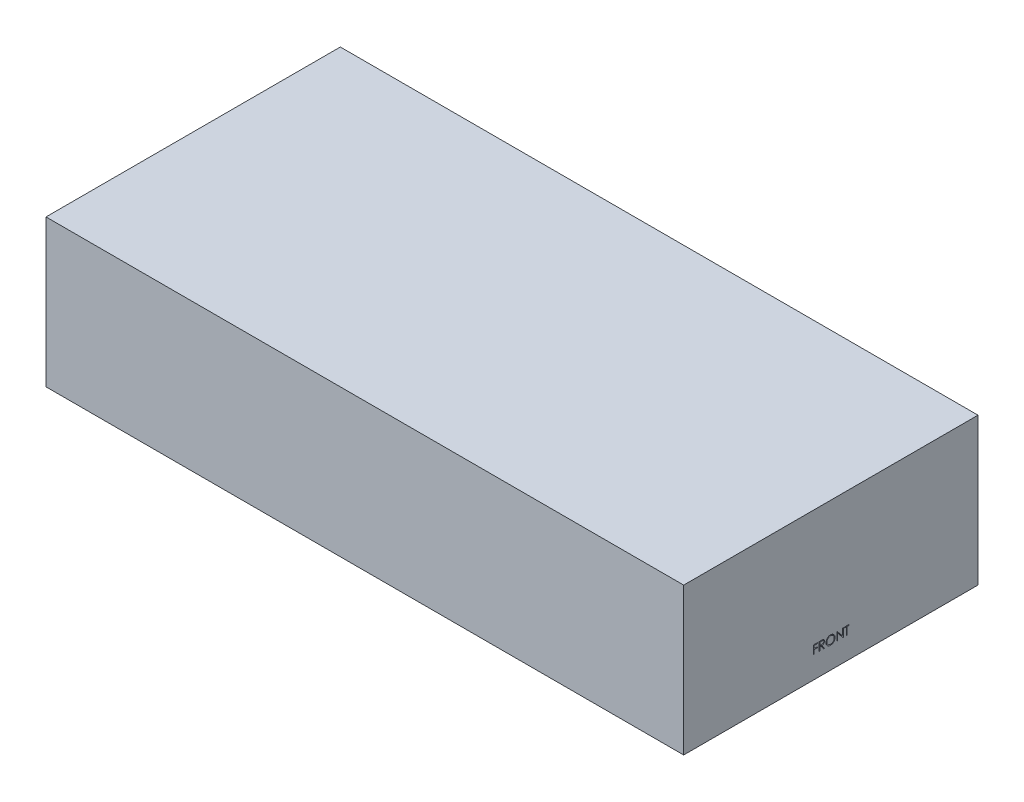
from build123d import *

# Parameters (mm, degrees)
SKETCH1_W           = 260
SKETCH1_H           = 120
BOSS_EXTRUDE1_DEPTH = 60
CUT_EXTRUDE1_DEPTH  = 1


with BuildPart() as part:
    # Sketch1 → Boss-Extrude1 (new body)
    with BuildSketch(Plane(origin=(0, 0, 0), x_dir=(1, 0, 0), z_dir=(0, 1, 0))):
        Rectangle(SKETCH1_W, SKETCH1_H)
    extrude(amount=BOSS_EXTRUDE1_DEPTH)

    # Sketch2 → Cut-Extrude1 (cut)
    # profile 1 of 5: a face of its own
    with BuildSketch(Plane(origin=(130, 0, 0), x_dir=(0, 0, -1), z_dir=(1, 0, 0))):
        Polygon((-7.08974359, 12.415972118), (-5.384615385, 12.415972118), (-5.384615385, 12.056997759), (-6.775641026, 12.056997759), (-6.775641026, 10.980074682), (-5.384615385, 10.980074682), (-5.384615385, 10.621100323), (-6.775641026, 10.621100323), (-6.775641026, 8.915972118), (-7.08974359, 8.915972118), align=None)
    # profile 2 of 5: a face of its own
    with BuildSketch(Plane(origin=(130, 0, 0), x_dir=(0, 0, -1), z_dir=(1, 0, 0))):
        with BuildLine():
            Line((-4.756410256, 12.415972118), (-4.055989583, 12.415972118))
            add(Edge.make_bspline(
                [(-4.055989583, 12.415972118), (-4.009248455, 12.415816532), (-3.91950031, 12.41551779), (-3.79092704, 12.413852027), (-3.674099943, 12.409077671), (-3.569080104, 12.404969088), (-3.475869449, 12.397477147), (-3.394182158, 12.390316499), (-3.324394461, 12.380942839), (-3.282148609, 12.372237416), (-3.263020833, 12.368295836)],
                knots=[0, 0, 0, 0, 1.410062039, 2.707475311, 3.878576406, 4.937260626, 5.877586885, 6.699081471, 7.410979367, 8, 8, 8, 8], degree=3))
            add(Edge.make_bspline(
                [(-3.263020833, 12.368295836), (-3.237414209, 12.361969071), (-3.18674722, 12.349450507), (-3.113797154, 12.322990906), (-3.04428283, 12.292371282), (-2.978493005, 12.256407561), (-2.916757214, 12.214832782), (-2.858438903, 12.168364659), (-2.80327344, 12.117257454), (-2.75349181, 12.060222612), (-2.706552758, 12.000386102), (-2.666964132, 11.935682346), (-2.632837652, 11.868020818), (-2.605667135, 11.7967134), (-2.583789161, 11.722451628), (-2.568362922, 11.644562832), (-2.559111734, 11.563401857), (-2.558169879, 11.508043948), (-2.557692308, 11.479974522)],
                knots=[0, 0, 0, 0, 1.027469482, 2.033020251, 3.019912614, 3.986113645, 4.951240523, 5.91722682, 6.890402269, 7.87763091, 8.8651537, 9.85103654, 10.82876324, 11.815024772, 12.821070561, 13.842952187, 14.906261191, 16, 16, 16, 16], degree=3))
            add(Edge.make_bspline(
                [(-2.557692308, 11.479974522), (-2.559161306, 11.433339418), (-2.562027702, 11.34234225), (-2.588752805, 11.210281368), (-2.632529325, 11.087092054), (-2.692852614, 10.972929416), (-2.76967209, 10.87001877), (-2.861996881, 10.779628315), (-2.969878492, 10.703988402), (-3.070307808, 10.651535598), (-3.159022008, 10.617942689), (-3.232055321, 10.59430633), (-3.311722298, 10.576044365), (-3.397259633, 10.559684233), (-3.489023288, 10.547332539), (-3.586793328, 10.538285944), (-3.690639479, 10.532631896), (-3.761978549, 10.531789891), (-3.798677885, 10.531356734)],
                knots=[0, 0, 0, 0, 1.260483769, 2.459530307, 3.627416485, 4.787058657, 5.939039949, 7.08810263, 8.267026773, 9.491475466, 10.141966685, 10.831826277, 11.566392101, 12.351337768, 13.187381173, 14.07005841, 15.007169909, 16, 16, 16, 16], degree=3))
            Line((-3.798677885, 10.531356734), (-2.512820513, 8.915972118))
            Line((-2.512820513, 8.915972118), (-2.901241987, 8.915972118))
            Line((-2.901241987, 8.915972118), (-4.187099359, 10.531356734))
            Line((-4.187099359, 10.531356734), (-4.442307692, 10.531356734))
            Line((-4.442307692, 10.531356734), (-4.442307692, 8.915972118))
            Line((-4.442307692, 8.915972118), (-4.756410256, 8.915972118))
            Line((-4.756410256, 8.915972118), (-4.756410256, 12.415972118))
        make_face()
        with BuildLine():
            Line((-4.442307692, 12.056997759), (-4.442307692, 10.890331093))
            Line((-4.442307692, 10.890331093), (-3.801482372, 10.88542324))
            add(Edge.make_bspline(
                [(-3.801482372, 10.88542324), (-3.771562333, 10.885410003), (-3.713568776, 10.885384347), (-3.629668111, 10.889378123), (-3.551547999, 10.893921441), (-3.479507247, 10.900870787), (-3.413513672, 10.909826859), (-3.353600259, 10.921029843), (-3.299669207, 10.934081906), (-3.236770668, 10.954283531), (-3.166534137, 10.98628955), (-3.090202677, 11.032855048), (-3.025200339, 11.091424168), (-2.970282477, 11.158397624), (-2.926153045, 11.232033872), (-2.895040991, 11.311450242), (-2.875298549, 11.39464184), (-2.872970003, 11.451819948), (-2.871794872, 11.480675644)],
                knots=[0, 0, 0, 0, 1.146690395, 2.22261258, 3.21895312, 4.145990853, 4.996080663, 5.770904154, 6.481378293, 7.121626537, 8.300444488, 9.431385265, 10.535395872, 11.636531494, 12.74115979, 13.810798291, 14.895190096, 16, 16, 16, 16], degree=3))
            add(Edge.make_bspline(
                [(-2.871794872, 11.480675644), (-2.872996993, 11.508822218), (-2.875379158, 11.564598456), (-2.894827927, 11.646254367), (-2.927717308, 11.723321317), (-2.972039546, 11.795485802), (-3.026038701, 11.860991538), (-3.089356514, 11.917038691), (-3.160261709, 11.963288155), (-3.226532907, 11.992842536), (-3.28576712, 12.010962389), (-3.33719678, 12.023713553), (-3.395308257, 12.033958022), (-3.460383716, 12.042166083), (-3.532145347, 12.049221027), (-3.610955998, 12.053972806), (-3.696292778, 12.05678667), (-3.755439709, 12.056925759), (-3.786057692, 12.056997759)],
                knots=[0, 0, 0, 0, 1.101028733, 2.181837193, 3.264309656, 4.369019818, 5.486613113, 6.575447106, 7.666700264, 8.788928104, 9.402425223, 10.0903467, 10.862060571, 11.710948788, 12.657782767, 13.684531032, 14.801375019, 16, 16, 16, 16], degree=3))
            Line((-3.786057692, 12.056997759), (-4.442307692, 12.056997759))
        make_face(mode=Mode.SUBTRACT)
    # profile 3 of 5: a face of its own
    with BuildSketch(Plane(origin=(130, 0, 0), x_dir=(0, 0, -1), z_dir=(1, 0, 0))):
        with BuildLine():
            add(Edge.make_bspline(
                [(-0.157051282, 12.505715708), (-0.092243176, 12.504074229), (0.035045291, 12.500850228), (0.222120189, 12.476171124), (0.400715284, 12.433475734), (0.572285423, 12.376612752), (0.734778399, 12.300758366), (0.889417292, 12.209073218), (1.035834166, 12.100596759), (1.172055547, 11.976167532), (1.296712497, 11.840784078), (1.406538384, 11.696306168), (1.498580677, 11.543607366), (1.574166464, 11.383146535), (1.633465074, 11.215286567), (1.674384118, 11.039132565), (1.700522268, 10.855825875), (1.703578045, 10.73079901), (1.705128205, 10.667374362)],
                knots=[0, 0, 0, 0, 1.065120563, 2.091984664, 3.0946048, 4.079830382, 5.057816894, 6.036188127, 7.030412546, 8.04752943, 9.064399622, 10.05169764, 11.02544977, 11.989514704, 12.962713494, 13.945757189, 14.957906945, 16, 16, 16, 16], degree=3))
            add(Edge.make_bspline(
                [(1.705128205, 10.667374362), (1.703578273, 10.604416916), (1.700523176, 10.480320495), (1.674354399, 10.298177051), (1.633313399, 10.123086354), (1.574717132, 9.955340702), (1.499491654, 9.794763138), (1.406836483, 9.641776184), (1.297695272, 9.496329686), (1.173488421, 9.36001702), (1.038087379, 9.23501955), (0.892857112, 9.126100674), (0.741063792, 9.032376549), (0.580754084, 8.957592875), (0.414054047, 8.897820955), (0.239471724, 8.857068325), (0.05782517, 8.830781282), (-0.066045834, 8.827762766), (-0.12900641, 8.826228529)],
                knots=[0, 0, 0, 0, 1.043624062, 2.057103931, 3.04512605, 4.022047818, 4.998200453, 5.980619268, 6.982898556, 8.009068085, 9.034988726, 10.034168286, 11.015286542, 11.987931943, 12.962482838, 13.94673481, 14.956375938, 16, 16, 16, 16], degree=3))
            add(Edge.make_bspline(
                [(-0.12900641, 8.826228529), (-0.192430729, 8.827777915), (-0.317456945, 8.830832169), (-0.500993981, 8.857013574), (-0.677271724, 8.897954878), (-0.845786076, 8.956464314), (-1.006631005, 9.032081545), (-1.160121088, 9.124285924), (-1.305640235, 9.233693065), (-1.441981982, 9.35785964), (-1.56673118, 9.493031192), (-1.675490556, 9.637865447), (-1.767715669, 9.789520903), (-1.843079001, 9.948418428), (-1.902743461, 10.11378987), (-1.943448279, 10.286738348), (-1.969784231, 10.466277854), (-1.972819077, 10.588520752), (-1.974358974, 10.650547439)],
                knots=[0, 0, 0, 0, 1.053102029, 2.075944431, 3.073151272, 4.055350789, 5.033113405, 6.020478099, 7.024410459, 8.052272461, 9.079885166, 10.07527673, 11.055994387, 12.023226415, 12.992069828, 13.970394897, 14.97016774, 16, 16, 16, 16], degree=3))
            add(Edge.make_bspline(
                [(-1.974358974, 10.650547439), (-1.973824339, 10.692180108), (-1.972761813, 10.774920231), (-1.95997012, 10.897786832), (-1.941408419, 11.018677489), (-1.914806506, 11.137248437), (-1.880014839, 11.253209422), (-1.838962812, 11.367360185), (-1.788822967, 11.478543909), (-1.732142319, 11.5872873), (-1.66888051, 11.691895206), (-1.599004761, 11.790774789), (-1.524969393, 11.884755786), (-1.443805999, 11.97140279), (-1.358189554, 12.053236446), (-1.266731176, 12.128999163), (-1.169988931, 12.199374114), (-1.067546551, 12.262794455), (-0.961928277, 12.32015359), (-0.853051499, 12.369375441), (-0.742394927, 12.411621502), (-0.629440279, 12.445862328), (-0.514487507, 12.472894364), (-0.397285723, 12.491301717), (-0.277928296, 12.504126035), (-0.197516978, 12.505183537), (-0.157051282, 12.505715708)],
                knots=[0, 0, 0, 0, 1.037015668, 2.060948919, 3.074880161, 4.083647147, 5.086022904, 6.090072063, 7.104153813, 8.122640571, 9.144368836, 10.147691507, 11.138137339, 12.123020368, 13.103399296, 14.087645067, 15.080126199, 16.082011238, 17.087798457, 18.072939717, 19.057185487, 20.037253025, 21.01195951, 21.997135196, 22.992090687, 24, 24, 24, 24], degree=3))
        make_face()
        with BuildLine():
            add(Edge.make_bspline(
                [(-0.141626603, 12.146741349), (-0.174841236, 12.146336459), (-0.240952969, 12.145530549), (-0.339237505, 12.134914833), (-0.436229439, 12.119784945), (-0.531948801, 12.098203424), (-0.625995091, 12.068799371), (-0.719244932, 12.034958463), (-0.810847986, 11.993737372), (-0.900501844, 11.947164668), (-0.987416919, 11.895615747), (-1.06942962, 11.83864398), (-1.146752264, 11.777585426), (-1.219195531, 11.712297588), (-1.286546703, 11.642447987), (-1.350131404, 11.56909555), (-1.407400986, 11.490143659), (-1.459886563, 11.407733253), (-1.506854403, 11.321971671), (-1.548619758, 11.233761809), (-1.582783767, 11.142384122), (-1.610646143, 11.048829965), (-1.633745954, 10.953247505), (-1.648379878, 10.854911656), (-1.659112237, 10.754316544), (-1.659872083, 10.68633469), (-1.66025641, 10.651949682)],
                knots=[0, 0, 0, 0, 1.008559885, 2.007477868, 2.99961109, 3.989939068, 4.984837346, 5.991145699, 7.001802488, 8.033829008, 9.059044045, 10.069351652, 11.065060232, 12.050310815, 13.029377138, 14.011219647, 14.996725999, 15.989392538, 16.977580475, 17.965360261, 18.951710183, 19.937753436, 20.929683414, 21.935841486, 22.955955122, 24, 24, 24, 24], degree=3))
            add(Edge.make_bspline(
                [(-1.66025641, 10.651949682), (-1.658981548, 10.601387462), (-1.6564735, 10.501915931), (-1.63451593, 10.356147787), (-1.600693956, 10.216059501), (-1.550836589, 10.082417592), (-1.488485975, 9.954073309), (-1.411459084, 9.832165204), (-1.320199999, 9.71666033), (-1.216536472, 9.608365061), (-1.103213766, 9.509519257), (-0.982881036, 9.422755848), (-0.856827428, 9.349345598), (-0.724724226, 9.289540526), (-0.587276687, 9.242150788), (-0.443599136, 9.209672157), (-0.294648676, 9.188296702), (-0.193118021, 9.186243946), (-0.141626603, 9.185202888)],
                knots=[0, 0, 0, 0, 1.032063989, 2.030389145, 3.003944642, 3.970395727, 4.937377036, 5.913328081, 6.909231446, 7.93887556, 8.970685674, 9.976071282, 10.964166581, 11.944589148, 12.933237628, 13.927779006, 14.949070134, 16, 16, 16, 16], degree=3))
            add(Edge.make_bspline(
                [(-0.141626603, 9.185202888), (-0.107017101, 9.185678392), (-0.038376065, 9.18662146), (0.063719458, 9.196120137), (0.16397567, 9.211352006), (0.262251949, 9.233282662), (0.358436761, 9.260729868), (0.452931564, 9.293337596), (0.544729854, 9.3340188), (0.634989692, 9.378966751), (0.721385934, 9.430206909), (0.803861466, 9.485245059), (0.880337446, 9.546213679), (0.952726517, 9.610531492), (1.020354206, 9.67949534), (1.08276319, 9.753015562), (1.139743323, 9.831556219), (1.192208969, 9.913841624), (1.239012232, 9.999837877), (1.279791331, 10.088367555), (1.314387447, 10.179212664), (1.342315952, 10.272504236), (1.364201413, 10.368065085), (1.379281333, 10.466023163), (1.389829772, 10.566182505), (1.390624849, 10.633926361), (1.391025641, 10.668075484)],
                knots=[0, 0, 0, 0, 1.047197238, 2.076906641, 3.100256066, 4.114471768, 5.12198147, 6.126382909, 7.136867548, 8.15857795, 9.17633901, 10.174870724, 11.156907918, 12.133735059, 13.104061851, 14.077631395, 15.04955518, 16.038496417, 17.029181396, 18.010275684, 18.986308667, 19.968651475, 20.955262928, 21.950658345, 22.966943676, 24, 24, 24, 24], degree=3))
            add(Edge.make_bspline(
                [(1.391025641, 10.668075484), (1.390624528, 10.701990988), (1.389828847, 10.769268638), (1.379286372, 10.868729456), (1.364185482, 10.965982668), (1.342422774, 11.060646471), (1.31437262, 11.152744996), (1.279785289, 11.242191744), (1.23899999, 11.329319939), (1.192191766, 11.413914236), (1.139575942, 11.495088974), (1.082081699, 11.572691386), (1.018716351, 11.645264128), (0.951290326, 11.714598822), (0.87811944, 11.779216711), (0.799535146, 11.839139232), (0.716491469, 11.895812506), (0.628564233, 11.946938068), (0.537820279, 11.994152301), (0.444706321, 12.034603304), (0.350277222, 12.068975423), (0.254773109, 12.098292388), (0.157390131, 12.119700418), (0.058786302, 12.134928468), (-0.040901956, 12.145526854), (-0.107945176, 12.146335233), (-0.141626603, 12.146741349)],
                knots=[0, 0, 0, 0, 1.02996197, 2.043119294, 3.035359645, 4.018872909, 4.991431989, 5.957985074, 6.929999688, 7.912076566, 8.892894881, 9.867085534, 10.843653904, 11.817741046, 12.803660682, 13.806313499, 14.818574707, 15.856120519, 16.894564902, 17.924820532, 18.937903209, 19.946497019, 20.957711757, 21.963978472, 22.977135795, 24, 24, 24, 24], degree=3))
        make_face(mode=Mode.SUBTRACT)
    # profile 4 of 5: a face of its own
    with BuildSketch(Plane(origin=(130, 0, 0), x_dir=(0, 0, -1), z_dir=(1, 0, 0))):
        Polygon((2.423076923, 8.915972118), (2.423076923, 12.415972118), (2.488982372, 12.415972118), (4.801282051, 9.661264586), (4.801282051, 12.415972118), (5.115384615, 12.415972118), (5.115384615, 8.915972118), (5.043870192, 8.915972118), (2.737179487, 11.664369554), (2.737179487, 8.915972118), align=None)
    # profile 5 of 5: a face of its own
    with BuildSketch(Plane(origin=(130, 0, 0), x_dir=(0, 0, -1), z_dir=(1, 0, 0))):
        Polygon((5.608974359, 12.056997759), (5.608974359, 12.415972118), (7.448717949, 12.415972118), (7.448717949, 12.056997759), (6.685897436, 12.056997759), (6.685897436, 8.915972118), (6.371794872, 8.915972118), (6.371794872, 12.056997759), align=None)
    extrude(amount=-CUT_EXTRUDE1_DEPTH, mode=Mode.SUBTRACT)


solid = part.part
